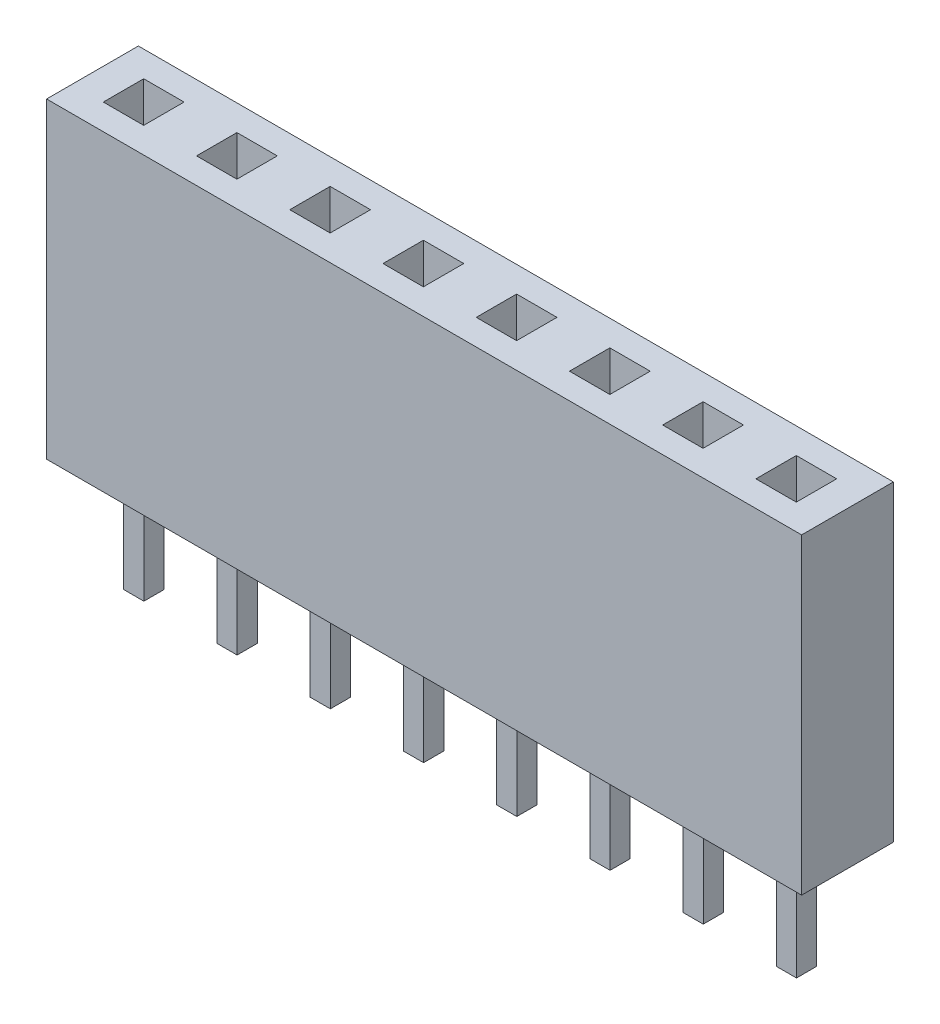
from build123d import *

# Parameters (mm, degrees)
SKETCH1_W             = 20.57
SKETCH1_H             = 8.5
BOSS_EXTRUDE1_DEPTH   = 1.25
SKETCH2_W             = 1.1
SKETCH2_H             = 1.1
CUT_EXTRUDE1_DEPTH    = 23.292092769
SKETCH3_W             = 20.57
SKETCH3_H             = 2.5
BOSS_EXTRUDE2_DEPTH   = 1
SKETCH4_W             = 0.55
SKETCH4_H             = 0.55
BOSS_EXTRUDE3_DEPTH   = 3
BOSS_EXTRUDE3_2_DEPTH = 3
BOSS_EXTRUDE3_3_DEPTH = 3
BOSS_EXTRUDE3_4_DEPTH = 3
BOSS_EXTRUDE3_5_DEPTH = 3
BOSS_EXTRUDE3_6_DEPTH = 3
BOSS_EXTRUDE3_7_DEPTH = 3
BOSS_EXTRUDE3_8_DEPTH = 3


with BuildPart() as part:
    # Sketch1 → Boss-Extrude1 (new, symmetric)
    with BuildSketch(Plane.XY):
        with Locations((10.285, 4.25)):
            Rectangle(SKETCH1_W, SKETCH1_H)
    extrude(amount=BOSS_EXTRUDE1_DEPTH, both=True)

    # Sketch2 → Cut-Extrude1 (cut, through all)
    with BuildSketch(Plane.XZ):
        with Locations((3.935, 0)):
            Rectangle(SKETCH2_W, SKETCH2_H)
        with Locations((1.395, 0)):
            Rectangle(SKETCH2_W, SKETCH2_H)
        with Locations((6.475, 0)):
            Rectangle(SKETCH2_W, SKETCH2_H)
        with Locations((9.015, 0)):
            Rectangle(SKETCH2_W, SKETCH2_H)
        with Locations((11.555, 0)):
            Rectangle(SKETCH2_W, SKETCH2_H)
        with Locations((14.095, 0)):
            Rectangle(SKETCH2_W, SKETCH2_H)
        with Locations((16.635, 0)):
            Rectangle(SKETCH2_W, SKETCH2_H)
        with Locations((19.175, 0)):
            Rectangle(SKETCH2_W, SKETCH2_H)
    extrude(amount=-CUT_EXTRUDE1_DEPTH, mode=Mode.SUBTRACT)

    # Sketch3 → Boss-Extrude2 (add)
    with BuildSketch(Plane.XZ):
        with Locations((10.285, 0)):
            Rectangle(SKETCH3_W, SKETCH3_H)
    extrude(amount=-BOSS_EXTRUDE2_DEPTH)


with BuildPart() as body_2:
    # Sketch4 → Boss-Extrude3 (new body)
    with BuildSketch(Plane.XZ):
        with Locations((1.4, 0)):
            Rectangle(SKETCH4_W, SKETCH4_H)
    extrude(amount=BOSS_EXTRUDE3_DEPTH)


with BuildPart() as body_3:
    # Sketch4 → Boss-Extrude3 2 (new body)
    with BuildSketch(Plane.XZ):
        with Locations((3.94, 0)):
            Rectangle(SKETCH4_W, SKETCH4_H)
    extrude(amount=BOSS_EXTRUDE3_2_DEPTH)


with BuildPart() as body_4:
    # Sketch4 → Boss-Extrude3 3 (new body)
    with BuildSketch(Plane.XZ):
        with Locations((6.48, 0)):
            Rectangle(SKETCH4_W, SKETCH4_H)
    extrude(amount=BOSS_EXTRUDE3_3_DEPTH)


with BuildPart() as body_5:
    # Sketch4 → Boss-Extrude3 4 (new body)
    with BuildSketch(Plane.XZ):
        with Locations((9.02, 0)):
            Rectangle(SKETCH4_W, SKETCH4_H)
    extrude(amount=BOSS_EXTRUDE3_4_DEPTH)


with BuildPart() as body_6:
    # Sketch4 → Boss-Extrude3 5 (new body)
    with BuildSketch(Plane.XZ):
        with Locations((11.56, 0)):
            Rectangle(SKETCH4_W, SKETCH4_H)
    extrude(amount=BOSS_EXTRUDE3_5_DEPTH)


with BuildPart() as body_7:
    # Sketch4 → Boss-Extrude3 6 (new body)
    with BuildSketch(Plane.XZ):
        with Locations((14.1, 0)):
            Rectangle(SKETCH4_W, SKETCH4_H)
    extrude(amount=BOSS_EXTRUDE3_6_DEPTH)


with BuildPart() as body_8:
    # Sketch4 → Boss-Extrude3 7 (new body)
    with BuildSketch(Plane.XZ):
        with Locations((16.64, 0)):
            Rectangle(SKETCH4_W, SKETCH4_H)
    extrude(amount=BOSS_EXTRUDE3_7_DEPTH)


with BuildPart() as body_9:
    # Sketch4 → Boss-Extrude3 8 (new body)
    with BuildSketch(Plane.XZ):
        with Locations((19.18, 0)):
            Rectangle(SKETCH4_W, SKETCH4_H)
    extrude(amount=BOSS_EXTRUDE3_8_DEPTH)


solid = Compound([part.part, body_2.part, body_3.part, body_4.part, body_5.part, body_6.part, body_7.part, body_8.part, body_9.part])
